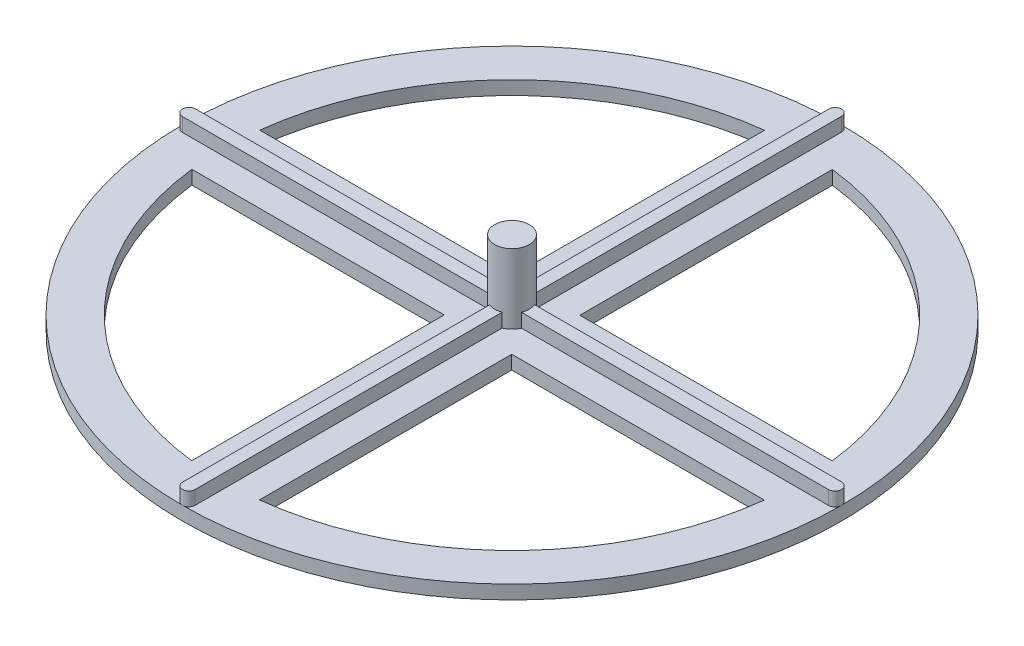
from build123d import *

# Parameters (mm, degrees)
SKETCH1_R                = 76.2
BOSS_EXTRUDE1_DEPTH      = 3.175
BOSS_EXTRUDE2_DEPTH      = 3.175
SKETCH3_R                = 4
BOSS_EXTRUDE3_DEPTH      = 12.954
BOSS_EXTRUDE3_DEPTH_BACK = 6.35
CUT_EXTRUDE1_DEPTH       = 4.175


with BuildPart() as part:
    # Sketch1 → Boss-Extrude1 (new body)
    with BuildSketch(Plane(origin=(0, 0, 0), x_dir=(1, 0, 0), z_dir=(0, 1, 0))):
        Circle(SKETCH1_R)
    extrude(amount=BOSS_EXTRUDE1_DEPTH)

    # Sketch2 → Boss-Extrude2 (add)
    with BuildSketch(Plane(origin=(0, 3.175, 0), x_dir=(1, 0, 0), z_dir=(0, 1, 0))):
        with BuildLine():
            Line((-74.676, 1.524), (74.676, 1.524))
            ThreePointArc((74.676, 1.524), (76.2, 0), (74.676, -1.524))
            Line((74.676, -1.524), (-74.676, -1.524))
            ThreePointArc((-74.676, -1.524), (-76.2, 0), (-74.676, 1.524))
        make_face()
        with BuildLine():
            Line((1.4605, 74.7395), (1.4605, -74.7395))
            ThreePointArc((1.4605, -74.7395), (0, -76.2), (-1.4605, -74.7395))
            Line((-1.4605, -74.7395), (-1.4605, 74.7395))
            ThreePointArc((-1.4605, 74.7395), (0, 76.2), (1.4605, 74.7395))
        make_face()
    extrude(amount=BOSS_EXTRUDE2_DEPTH)

    # Sketch3 → Boss-Extrude3 (add, two sides)
    with BuildSketch(Plane(origin=(0, 6.35, 0), x_dir=(1, 0, 0), z_dir=(0, 1, 0))) as boss_extrude3_sk:
        Circle(SKETCH3_R)
    extrude(amount=BOSS_EXTRUDE3_DEPTH)
    extrude(boss_extrude3_sk.sketch, amount=-BOSS_EXTRUDE3_DEPTH_BACK)

    # Sketch4 → Cut-Extrude1 (cut, through all)
    with BuildSketch(Plane(origin=(0, 3.175, 0), x_dir=(1, 0, 0), z_dir=(0, 1, 0))):
        with BuildLine():
            Line((-7.8105, 7.874), (-39.5605, 7.874))
            Line((-39.5605, 7.874), (-63.009920838, 7.874))
            Line((-63.009920838, 7.874), (-66.208426571, 7.874))
            ThreePointArc((-66.208426571, 7.874), (-47.123731651, 47.168946779), (-7.8105, 66.215947586))
            Line((-7.8105, 66.215947586), (-7.8105, 63.017823588))
            Line((-7.8105, 63.017823588), (-7.8105, 7.874))
        make_face()
        with BuildLine():
            Line((7.874, 63.009920838), (7.874, 66.208426571))
            ThreePointArc((7.874, 66.208426571), (47.168946779, 47.123731651), (66.215947586, 7.8105))
            Line((66.215947586, 7.8105), (63.017823588, 7.8105))
            Line((63.017823588, 7.8105), (7.874, 7.8105))
            Line((7.874, 7.8105), (7.874, 39.5605))
            Line((7.874, 39.5605), (7.874, 63.009920838))
        make_face()
        with BuildLine():
            Line((63.009920838, -7.874), (66.208426571, -7.874))
            ThreePointArc((66.208426571, -7.874), (47.123731651, -47.168946779), (7.8105, -66.215947586))
            Line((7.8105, -66.215947586), (7.8105, -63.017823588))
            Line((7.8105, -63.017823588), (7.8105, -7.874))
            Line((7.8105, -7.874), (39.5605, -7.874))
            Line((39.5605, -7.874), (63.009920838, -7.874))
        make_face()
        with BuildLine():
            Line((-7.874, -63.009920838), (-7.874, -66.208426571))
            ThreePointArc((-7.874, -66.208426571), (-47.168946779, -47.123731651), (-66.215947586, -7.8105))
            Line((-66.215947586, -7.8105), (-63.017823588, -7.8105))
            Line((-63.017823588, -7.8105), (-7.874, -7.8105))
            Line((-7.874, -7.8105), (-7.874, -39.5605))
            Line((-7.874, -39.5605), (-7.874, -63.009920838))
        make_face()
    extrude(amount=-CUT_EXTRUDE1_DEPTH, mode=Mode.SUBTRACT)


solid = part.part
